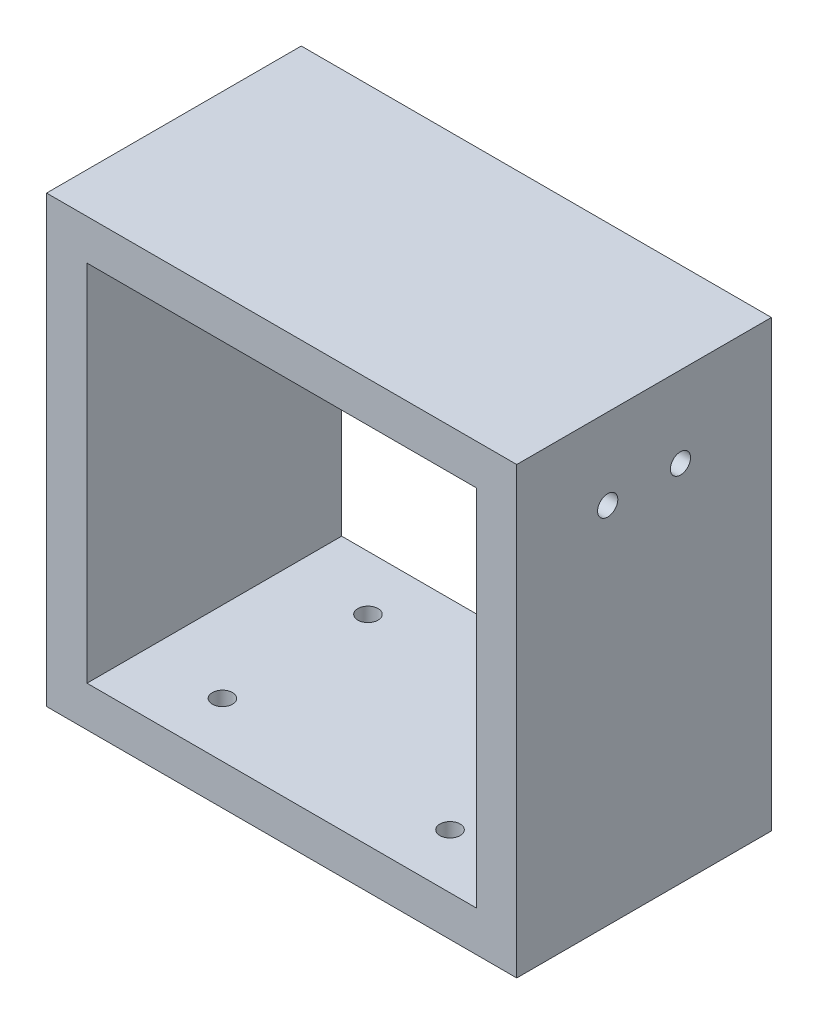
from build123d import *

# Parameters (mm, degrees)
SKETCH_1_W          = 58.15
SKETCH_1_H          = 31.5
EXTRUDE_1_DEPTH     = 55
SKETCH_2_W          = 48.15
SKETCH_2_H          = 45
CUT_EXTRUDE_1_DEPTH = 31.5
SKETCH_4_R          = 1.25
CUT_EXTRUDE_2_DEPTH = 10
SKETCH_5_R          = 1.25
CUT_EXTRUDE_3_DEPTH = 10
SKETCH_6_R          = 1.25
CUT_EXTRUDE_4_DEPTH = 20.7
SKETCH_7_R          = 1.25
CUT_EXTRUDE_5_DEPTH = 20.7


with BuildPart() as part:
    # 草图1 → 凸台-拉伸1 (new body)
    with BuildSketch(Plane(origin=(0, 0, 0), x_dir=(1, 0, 0), z_dir=(0, 1, 0))):
        with Locations((29.075, 15.75)):
            Rectangle(SKETCH_1_W, SKETCH_1_H)
    extrude(amount=-EXTRUDE_1_DEPTH)

    # 草图2 → 切除-拉伸1 (cut)
    with BuildSketch(Plane.XY):
        with Locations((29.075, -27.5)):
            Rectangle(SKETCH_2_W, SKETCH_2_H)
    extrude(amount=-CUT_EXTRUDE_1_DEPTH, mode=Mode.SUBTRACT)

    # 草图4 → 切除-拉伸2 (cut)
    with BuildSketch(Plane.XZ.offset(55)):
        with Locations((15, -6.75)):
            Circle(SKETCH_4_R)
        with Locations((43.15, -6.75)):
            Circle(SKETCH_4_R)
    extrude(amount=-CUT_EXTRUDE_2_DEPTH, mode=Mode.SUBTRACT)

    # 草图5 → 切除-拉伸3 (cut)
    with BuildSketch(Plane.XZ.offset(55)):
        with Locations((43.15, -24.75)):
            Circle(SKETCH_5_R)
        with Locations((15, -24.75)):
            Circle(SKETCH_5_R)
    extrude(amount=-CUT_EXTRUDE_3_DEPTH, mode=Mode.SUBTRACT)

    # 草图6 → 切除-拉伸4 (cut)
    with BuildSketch(Plane(origin=(5, 0, 0), x_dir=(0, 0, -1), z_dir=(1, 0, 0))):
        with Locations((11.25, -10)):
            Circle(SKETCH_6_R)
        with Locations((20.25, -10)):
            Circle(SKETCH_6_R)
    extrude(amount=-CUT_EXTRUDE_4_DEPTH, mode=Mode.SUBTRACT)

    # 草图7 → 切除-拉伸5 (cut)
    with BuildSketch(Plane(origin=(58.15, 0, 0), x_dir=(0, 0, -1), z_dir=(1, 0, 0))):
        with Locations((20.25, -10)):
            Circle(SKETCH_7_R)
        with Locations((11.25, -10)):
            Circle(SKETCH_7_R)
    extrude(amount=-CUT_EXTRUDE_5_DEPTH, mode=Mode.SUBTRACT)


solid = part.part
